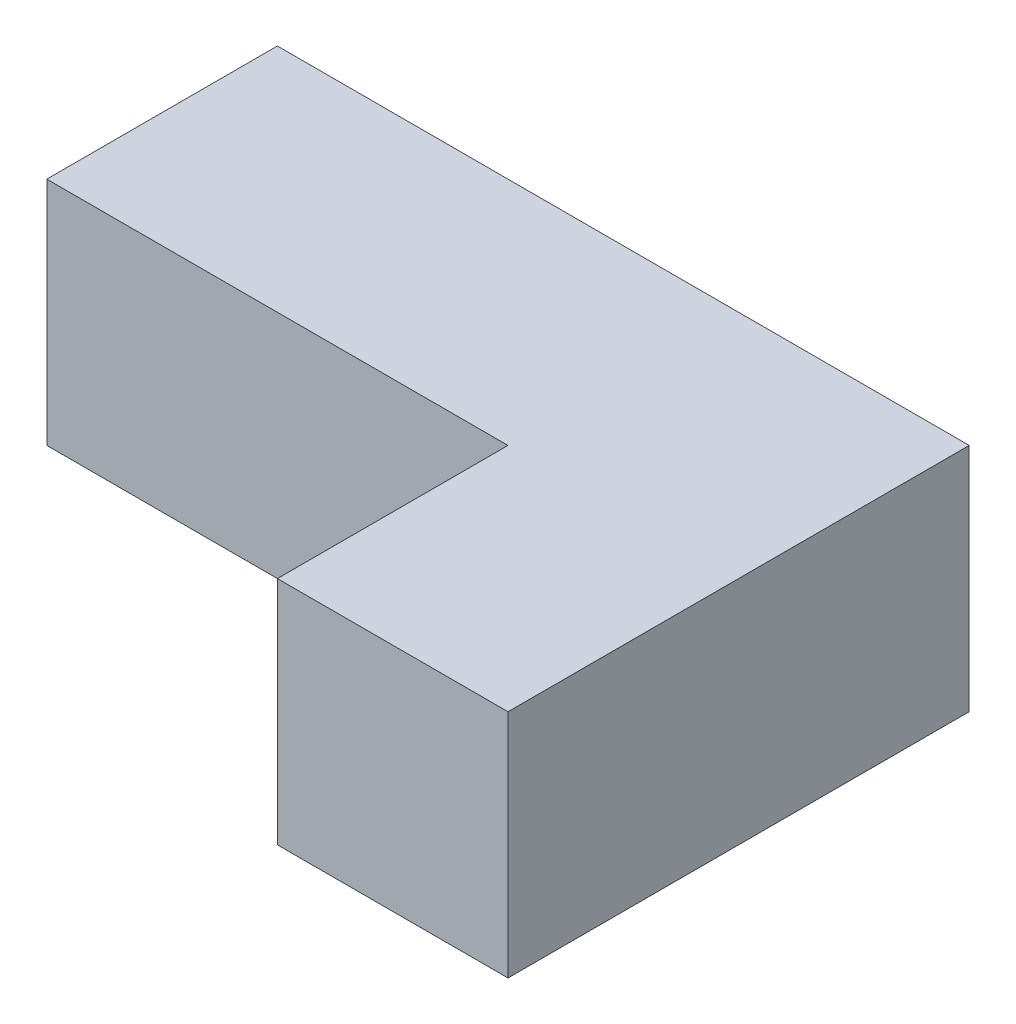
from build123d import *

# Parameters (mm, degrees)
SKETCH1_W           = 76.2
SKETCH1_H           = 50.8
BOSS_EXTRUDE1_DEPTH = 25.4
SKETCH2_W           = 50.8
SKETCH2_H           = 25.4
CUT_EXTRUDE1_DEPTH  = 26.4


with BuildPart() as part:
    # Sketch1 → Boss-Extrude1 (new body)
    with BuildSketch(Plane(origin=(0, 0, 0), x_dir=(1, 0, 0), z_dir=(0, 1, 0))):
        Rectangle(SKETCH1_W, SKETCH1_H)
    extrude(amount=BOSS_EXTRUDE1_DEPTH)

    # Sketch2 → Cut-Extrude1 (cut, through all)
    with BuildSketch(Plane(origin=(0, 25.4, 0), x_dir=(1, 0, 0), z_dir=(0, 1, 0))):
        with Locations((-12.7, -12.7)):
            Rectangle(SKETCH2_W, SKETCH2_H)
    extrude(amount=-CUT_EXTRUDE1_DEPTH, mode=Mode.SUBTRACT)


solid = part.part
